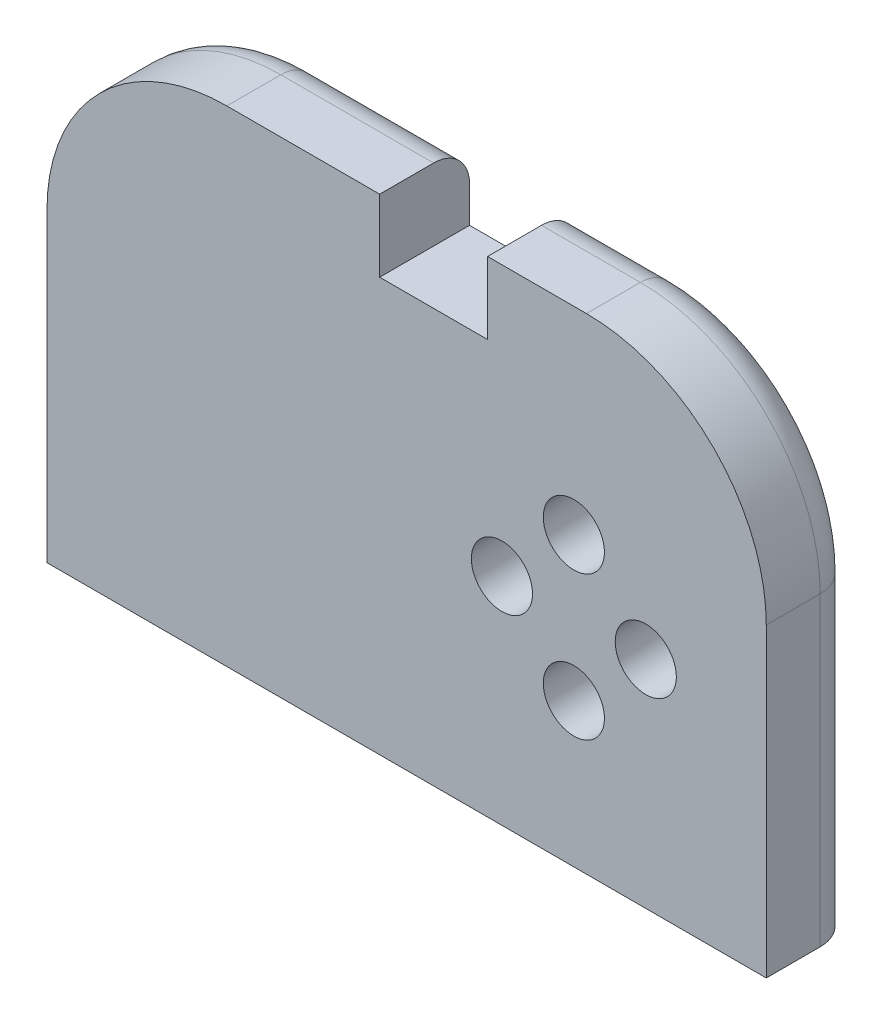
from build123d import *

# Parameters (mm, degrees)
EXTRUDE_1_DEPTH        = 5
FILLET_1_R             = 10
FILLET_2_R             = 2
HOLE_WIZARD_M2_1_D     = 1.6
HOLE_WIZARD_M2_1_DEPTH = 4
HOLE_WIZARD_M2_1_TIP   = 0.480688495
HOLE_WIZARD_M3_1_D     = 3.4
HOLE_WIZARD_M3_1_DEPTH = 5.6
HOLE_WIZARD_M3_1_TIP   = 1.021463052


with BuildPart() as part:
    # 스케치1 → 보스-돌출1 (new body)
    with BuildSketch(Plane.XY):
        Polygon((-1.5, 13.5), (-1.5, 9.5), (4.5, 9.5), (4.5, 13.5), (20, 13.5), (20, -13.5), (-20, -13.5), (-20, 13.5), align=None)
    extrude(amount=EXTRUDE_1_DEPTH)

    # 필렛1
    fillet_1_edges = [part.edges().sort_by_distance(p)[0] for p in [
        (-20, 13.5, 2.5),
        (20, 13.5, 2.5),
    ]]
    fillet(fillet_1_edges, radius=FILLET_1_R)

    # 필렛2
    fillet_2_edges = [part.edges().sort_by_distance(p)[0] for p in [
        (20, -5, 0),
        (-20, -5, 0),
        (7.25, 13.5, 0),
        (17.071067812, 10.571067812, 0),
        (-17.071067812, 10.571067812, 0),
        (-5.75, 13.5, 0),
    ]]
    fillet(fillet_2_edges, radius=FILLET_2_R)

    # M2 나사 구멍1
    with Locations(Plane(origin=(0, -13.5, 0), x_dir=(-1, 0, 0), z_dir=(0, -1, 0))):
        with Locations((12.5, -3), (0, -3), (-12.5, -3)):
            Hole(HOLE_WIZARD_M2_1_D / 2, depth=HOLE_WIZARD_M2_1_DEPTH)
            with Locations((0, 0, -(HOLE_WIZARD_M2_1_DEPTH + HOLE_WIZARD_M2_1_TIP / 2))):  # 118° drill point
                Cone(0, HOLE_WIZARD_M2_1_D / 2, HOLE_WIZARD_M2_1_TIP, mode=Mode.SUBTRACT)

    # M3 여유 구멍1
    with Locations(Plane(origin=(0, 0, 0), x_dir=(-1, 0, 0), z_dir=(0, 0, -1))):
        with Locations((-13.3, -1.5), (-9.3, 2.5), (-5.3, -1.5), (-9.3, -5.5)):
            Hole(HOLE_WIZARD_M3_1_D / 2, depth=HOLE_WIZARD_M3_1_DEPTH)
            with Locations((0, 0, -(HOLE_WIZARD_M3_1_DEPTH + HOLE_WIZARD_M3_1_TIP / 2))):  # 118° drill point
                Cone(0, HOLE_WIZARD_M3_1_D / 2, HOLE_WIZARD_M3_1_TIP, mode=Mode.SUBTRACT)


solid = part.part
